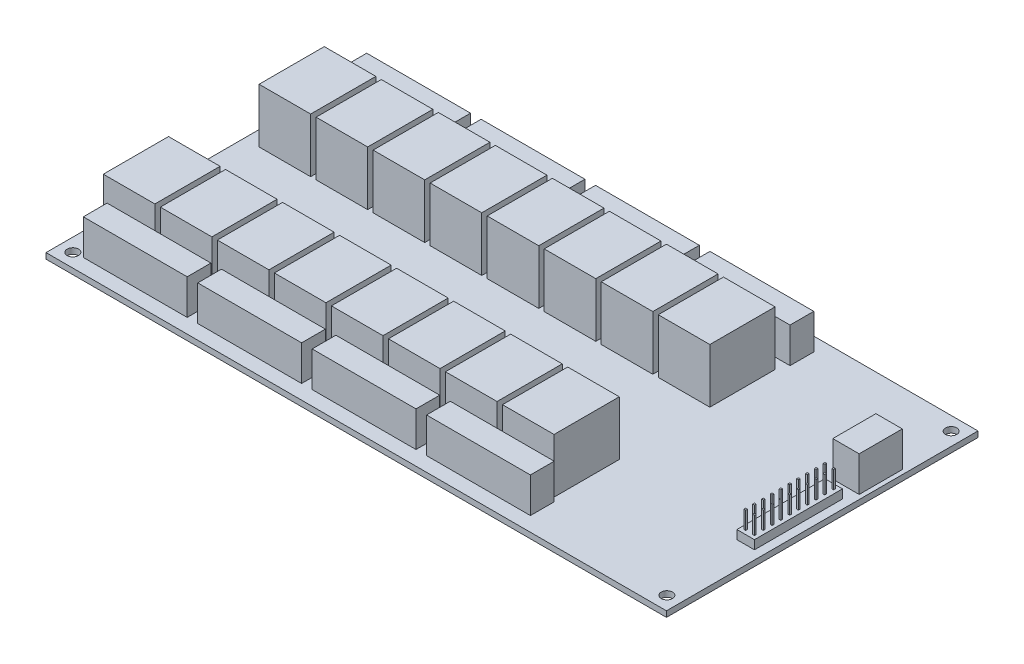
from build123d import *

# Parameters (mm, degrees)
SKETCH1_W                    = 179.07
SKETCH1_H                    = 89.916
BOSS_EXTRUDE1_DEPTH          = 1.651
F_30_0_1285_DIAMETER_HOLE1_D = 3.2639
SKETCH4_W                    = 14.8844
SKETCH4_H                    = 18.8214
BOSS_EXTRUDE2_DEPTH          = 15.6718
LPATTERN1_COUNT              = 8
LPATTERN1_PITCH              = 16.4592
LPATTERN1_COUNT_DIR2         = 2
LPATTERN1_PITCH_DIR2         = 44.958
SKETCH5_W                    = 29.972
SKETCH5_H                    = 6.858
BOSS_EXTRUDE3_DEPTH          = 10.16
LPATTERN2_COUNT              = 4
LPATTERN2_PITCH              = 33.02
LPATTERN2_COUNT_DIR2         = 2
LPATTERN2_PITCH_DIR2         = 74.93
SKETCH6_W                    = 7.62
SKETCH6_H                    = 12.452922763
BOSS_EXTRUDE4_DEPTH          = 10.16
SKETCH7_W                    = 5.08
SKETCH7_H                    = 25.4
BOSS_EXTRUDE5_DEPTH          = 2.54
SKETCH8_W                    = 0.508
SKETCH8_H                    = 0.508
BOSS_EXTRUDE6_DEPTH          = 5.08
LPATTERN3_COUNT              = 10
LPATTERN3_PITCH              = 2.54
LPATTERN3_COUNT_DIR2         = 2
LPATTERN3_PITCH_DIR2         = 2.54


with BuildPart() as part:
    # Sketch1 → Boss-Extrude1 (new body)
    with BuildSketch(Plane(origin=(0, 0, 0), x_dir=(1, 0, 0), z_dir=(0, 1, 0))):
        Rectangle(SKETCH1_W, SKETCH1_H)
    extrude(amount=BOSS_EXTRUDE1_DEPTH)

    # #30 (0.1285) Diameter Hole1 (through all)
    with Locations(Plane(origin=(-85.725, 1.651, 41.021), x_dir=(0, 0, 1), z_dir=(0, 1, 0))):
        with Locations((0, 0), (-82.042, 0), (-82.042, 171.45), (0, 171.45)):
            Hole(F_30_0_1285_DIAMETER_HOLE1_D / 2)

    # Sketch4 → Boss-Extrude2 (add)
    with BuildSketch(Plane(origin=(0, 1.651, 0), x_dir=(1, 0, 0), z_dir=(0, 1, 0))):
        with Locations((-77.7494, -23.3553)):
            Rectangle(SKETCH4_W, SKETCH4_H)
    boss_extrude2 = extrude(amount=BOSS_EXTRUDE2_DEPTH)

    # LPattern1: Boss-Extrude2 8 × 2
    with Locations(*[(i * LPATTERN1_PITCH, 0, -j * LPATTERN1_PITCH_DIR2) for i in range(LPATTERN1_COUNT) for j in range(LPATTERN1_COUNT_DIR2) if (i, j) != (0, 0)]):
        add(boss_extrude2)

    # Sketch5 → Boss-Extrude3 (add)
    with BuildSketch(Plane(origin=(0, 1.651, 0), x_dir=(1, 0, 0), z_dir=(0, 1, 0))):
        with Locations((-67.945, -37.3634)):
            Rectangle(SKETCH5_W, SKETCH5_H)
    boss_extrude3 = extrude(amount=BOSS_EXTRUDE3_DEPTH)

    # LPattern2: Boss-Extrude3 4 × 2
    with Locations(*[(i * LPATTERN2_PITCH, 0, -j * LPATTERN2_PITCH_DIR2) for i in range(LPATTERN2_COUNT) for j in range(LPATTERN2_COUNT_DIR2) if (i, j) != (0, 0)]):
        add(boss_extrude3)

    # Sketch6 → Boss-Extrude4 (add)
    with BuildSketch(Plane(origin=(0, 1.651, 0), x_dir=(1, 0, 0), z_dir=(0, 1, 0))):
        with Locations((84.455, 18.157538618)):
            Rectangle(SKETCH6_W, SKETCH6_H)
    extrude(amount=BOSS_EXTRUDE4_DEPTH)

    # Sketch7 → Boss-Extrude5 (add)
    with BuildSketch(Plane(origin=(0, 1.651, 0), x_dir=(1, 0, 0), z_dir=(0, 1, 0))):
        with Locations((84.455, -4.318)):
            Rectangle(SKETCH7_W, SKETCH7_H)
    extrude(amount=BOSS_EXTRUDE5_DEPTH)

    # Sketch8 → Boss-Extrude6 (add)
    with BuildSketch(Plane(origin=(0, 4.191, 0), x_dir=(1, 0, 0), z_dir=(0, 1, 0))):
        with Locations((85.725, 7.112)):
            Rectangle(SKETCH8_W, SKETCH8_H)
    boss_extrude6 = extrude(amount=BOSS_EXTRUDE6_DEPTH)

    # LPattern3: Boss-Extrude6 10 × 2
    with Locations(*[(-j * LPATTERN3_PITCH_DIR2, 0, i * LPATTERN3_PITCH) for i in range(LPATTERN3_COUNT) for j in range(LPATTERN3_COUNT_DIR2) if (i, j) != (0, 0)]):
        add(boss_extrude6)


solid = part.part
